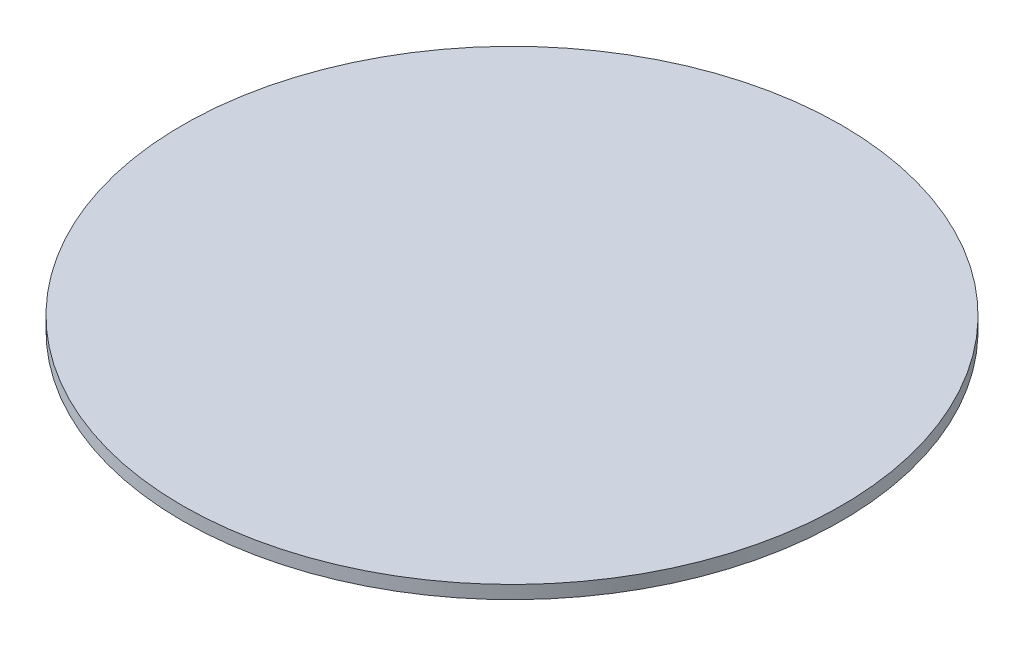
from build123d import *

# Parameters (mm, degrees)
SKETCH1_R           = 20
BOSS_EXTRUDE1_DEPTH = 0.8


with BuildPart() as part:
    # Sketch1 → Boss-Extrude1 (new body)
    with BuildSketch(Plane(origin=(0, 0, 0), x_dir=(1, 0, 0), z_dir=(0, 1, 0))):
        Circle(SKETCH1_R)
    extrude(amount=BOSS_EXTRUDE1_DEPTH)


solid = part.part
